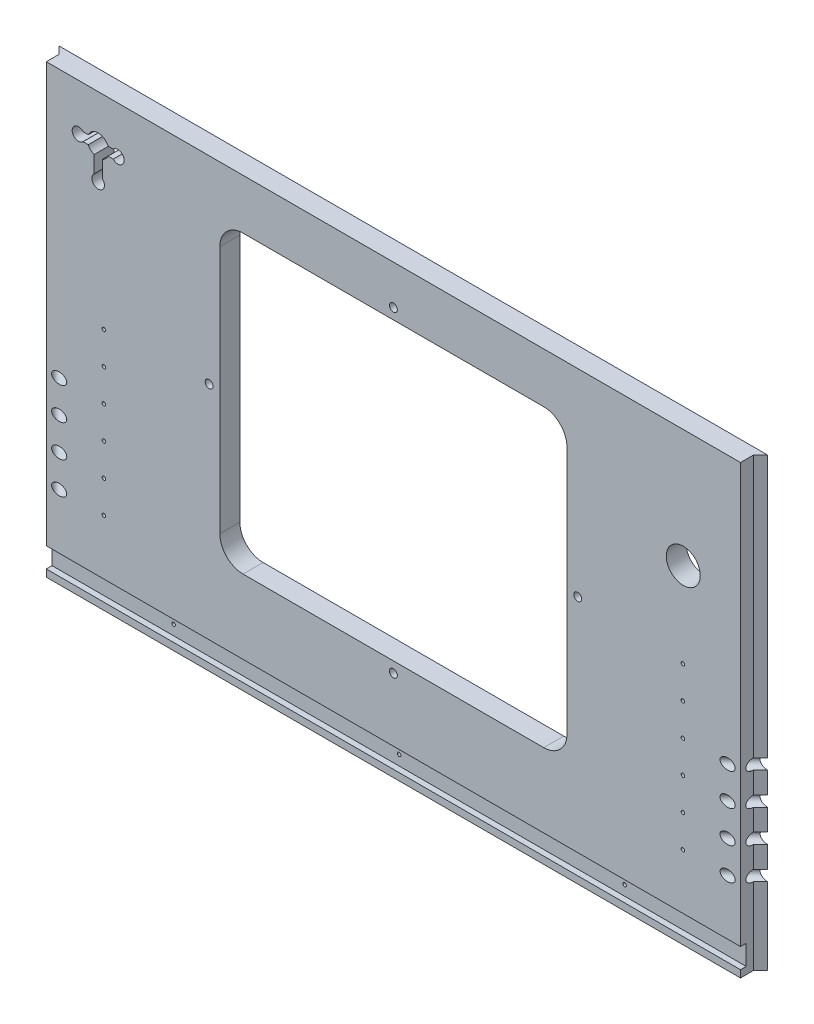
from build123d import *

# Parameters (mm, degrees)
CABFRONTOUTLINE_W               = 628.65
CABFRONTOUTLINE_H               = 396.08125
CABFRONT_THICKNESS_DEPTH        = 17.78
CABFRONT_COINDOORCUTS_R         = 1.5875
CUT_EXTRUDE1_DEPTH              = 12.7
SKETCH5_R                       = 15.08125
SKETCH5_R_2                     = 3.4925
SKETCH5_W                       = 308.0004
SKETCH5_H                       = 261.9629
CUT_EXTRUDE8_DEPTH              = 17.78
CABFRONTBOTTOMLEDGE_DEPTH_DEPTH = 5.08
CUT_EXTRUDE4_DEPTH              = 396.08125
FILLET1_R                       = 20.6502
SKETCH2_R                       = 4.7625
CUT_EXTRUDE5_DEPTH              = 76.2
SKETCH3_R                       = 4.7625
CUT_EXTRUDE6_DEPTH              = 76.2
SKETCH4_R                       = 4.7625
CUT_EXTRUDE7_DEPTH              = 76.2
SKETCH6_R                       = 4.7625
CUT_EXTRUDE9_DEPTH              = 76.2


with BuildPart() as part:
    # CabFrontOutline → CabFront_Thickness (new body)
    with BuildSketch(Plane.XY):
        with Locations((12009.966666666, -5854.303125)):
            Rectangle(CABFRONTOUTLINE_W, CABFRONTOUTLINE_H)
    extrude(amount=-CABFRONT_THICKNESS_DEPTH)

    # CabFront_CoinDoorCuts → Cut-Extrude1 (cut)
    with BuildSketch(Plane.XY):
        with Locations((11753.109166666, -5893.59375)):
            Circle(CABFRONT_COINDOORCUTS_R)
        with Locations((11753.109166666, -5950.74375)):
            Circle(CABFRONT_COINDOORCUTS_R)
        with Locations((12266.824166666, -5893.59375)):
            Circle(CABFRONT_COINDOORCUTS_R)
        with Locations((12266.824166666, -5950.74375)):
            Circle(CABFRONT_COINDOORCUTS_R)
        with Locations((11753.109166666, -5836.44375)):
            Circle(CABFRONT_COINDOORCUTS_R)
        with Locations((12266.824166666, -5836.44375)):
            Circle(CABFRONT_COINDOORCUTS_R)
        with Locations((12266.824166666, -5865.01875)):
            Circle(CABFRONT_COINDOORCUTS_R)
        with Locations((12266.824166666, -5922.16875)):
            Circle(CABFRONT_COINDOORCUTS_R)
        with Locations((12266.824166666, -5979.31875)):
            Circle(CABFRONT_COINDOORCUTS_R)
        with Locations((12209.991666666, -6037.10375)):
            Circle(CABFRONT_COINDOORCUTS_R)
        with Locations((12009.966666666, -6037.10375)):
            Circle(CABFRONT_COINDOORCUTS_R)
        with Locations((11809.941666666, -6037.10375)):
            Circle(CABFRONT_COINDOORCUTS_R)
        with Locations((11753.109166666, -5979.31875)):
            Circle(CABFRONT_COINDOORCUTS_R)
        with Locations((11753.109166666, -5922.16875)):
            Circle(CABFRONT_COINDOORCUTS_R)
        with Locations((11753.109166666, -5865.01875)):
            Circle(CABFRONT_COINDOORCUTS_R)
    extrude(amount=-CUT_EXTRUDE1_DEPTH, mode=Mode.SUBTRACT)

    # Sketch5 → Cut-Extrude8 (cut)
    with BuildSketch(Plane.XY):
        with Locations((12267.141666666, -5761.0375)):
            Circle(SKETCH5_R)
        with Locations((12173.479166666, -5831.68125)):
            Circle(SKETCH5_R_2)
        with Locations((11846.454166666, -5831.68125)):
            Circle(SKETCH5_R_2)
        with Locations((12009.966666666, -5972.175)):
            Circle(SKETCH5_R_2)
        with Locations((12009.966666666, -5691.1875)):
            Circle(SKETCH5_R_2)
        with Locations((12009.966666666, -5831.68125)):
            Rectangle(SKETCH5_W, SKETCH5_H)
        with BuildLine():
            Line((11734.654409808, -5693.754968556), (11739.23011943, -5693.754968556))
            ThreePointArc((11739.23011943, -5693.754968556), (11748.029166666, -5687.976468556), (11756.828213901, -5693.754968556))
            Line((11756.828213901, -5693.754968556), (11761.386355753, -5693.754968556))
            ThreePointArc((11761.386355753, -5693.754968556), (11767.531113043, -5692.357368906), (11771.079666666, -5697.564968556))
            ThreePointArc((11771.079666666, -5697.564968556), (11767.531113043, -5702.772568206), (11761.386355753, -5701.374968556))
            Line((11761.386355753, -5701.374968556), (11756.828213901, -5701.374968556))
            ThreePointArc((11756.828213901, -5701.374968556), (11754.760305425, -5704.393665595), (11751.712166666, -5706.417925308))
            Line((11751.712166666, -5706.417925308), (11751.712166666, -5721.30243896))
            ThreePointArc((11751.712166666, -5721.30243896), (11748.029166666, -5731.092968556), (11744.346166666, -5721.30243896))
            Line((11744.346166666, -5721.30243896), (11744.346166666, -5706.417925308))
            ThreePointArc((11744.346166666, -5706.417925308), (11741.298027907, -5704.393665595), (11739.23011943, -5701.374968556))
            Line((11739.23011943, -5701.374968556), (11734.654409809, -5701.374968556))
            ThreePointArc((11734.654409809, -5701.374968556), (11724.978666666, -5697.564968556), (11734.654409808, -5693.754968556))
        make_face()
    extrude(amount=-CUT_EXTRUDE8_DEPTH, mode=Mode.SUBTRACT)

    # CabFront_BottomLedge → CabFrontBottomLedge_Depth (cut)
    with BuildSketch(Plane.XY):
        Polygon((11975.041666666, -6028.21375), (11695.641666666, -6028.21375), (11695.641666666, -6045.99375), (12324.291666666, -6045.99375), (12324.291666666, -6028.21375), align=None)
    extrude(amount=-CABFRONTBOTTOMLEDGE_DEPTH_DEPTH, mode=Mode.SUBTRACT)

    # CabFront_EdgeBevel → Cut-Extrude4 (cut)
    with BuildSketch(Plane.XZ.offset(6052.34375)):
        Polygon((11701.991666666, -11.43), (11701.991666666, 0), (11695.641666666, 0), (11695.641666666, -17.78), align=None)
        Polygon((12317.941666666, -11.43), (12324.291666666, -17.78), (12324.291666666, 0), (12317.941666666, 0), align=None)
    extrude(amount=-CUT_EXTRUDE4_DEPTH, mode=Mode.SUBTRACT)

    # Fillet1
    fillet1_edges = [part.edges().sort_by_distance(p)[0] for p in [
        (11855.966466666, -5962.6627, -8.89),
        (11855.966466666, -5700.6998, -8.89),
        (12163.966866666, -5700.6998, -8.89),
        (12163.966866666, -5962.6627, -8.89),
    ]]
    fillet(fillet1_edges, radius=FILLET1_R)

    # Sketch2 → Cut-Extrude5 (cut)
    with BuildSketch(Plane(origin=(5872.794384557, 0, 5872.794384557), x_dir=(0.707106781, 0, -0.707106781), z_dir=(0.707106781, 0, 0.707106781))):
        with Locations((8282.639891397, -5922.16875)):
            Circle(SKETCH2_R)
        with Locations((8282.639891397, -5979.31875)):
            Circle(SKETCH2_R)
    extrude(amount=-CUT_EXTRUDE5_DEPTH, mode=Mode.SUBTRACT)

    # Sketch3 → Cut-Extrude6 (cut)
    with BuildSketch(Plane(origin=(6137.172282109, 0, -6137.172282109), x_dir=(0.707106781, 0, 0.707106781), z_dir=(-0.707106781, 0, 0.707106781))):
        with Locations((8702.017852251, -5922.16875)):
            Circle(SKETCH3_R)
        with Locations((8702.017852251, -5979.31875)):
            Circle(SKETCH3_R)
    extrude(amount=-CUT_EXTRUDE6_DEPTH, mode=Mode.SUBTRACT)

    # Sketch4 → Cut-Extrude7 (cut)
    with BuildSketch(Plane(origin=(6137.165932109, 0, -6137.165932109), x_dir=(0.707106781, 0, 0.707106781), z_dir=(-0.707106781, 0, 0.707106781))):
        with Locations((8702.008871995, -5950.74375)):
            Circle(SKETCH4_R)
        with Locations((8702.008871995, -5893.59375)):
            Circle(SKETCH4_R)
    extrude(amount=-CUT_EXTRUDE7_DEPTH, mode=Mode.SUBTRACT)

    # Sketch6 → Cut-Extrude9 (cut)
    with BuildSketch(Plane(origin=(5872.800734557, 0, 5872.800734557), x_dir=(0.707106781, 0, -0.707106781), z_dir=(0.707106781, 0, 0.707106781))):
        with Locations((8282.648871653, -5893.59375)):
            Circle(SKETCH6_R)
        with Locations((8282.648871653, -5950.74375)):
            Circle(SKETCH6_R)
    extrude(amount=-CUT_EXTRUDE9_DEPTH, mode=Mode.SUBTRACT)


solid = part.part
